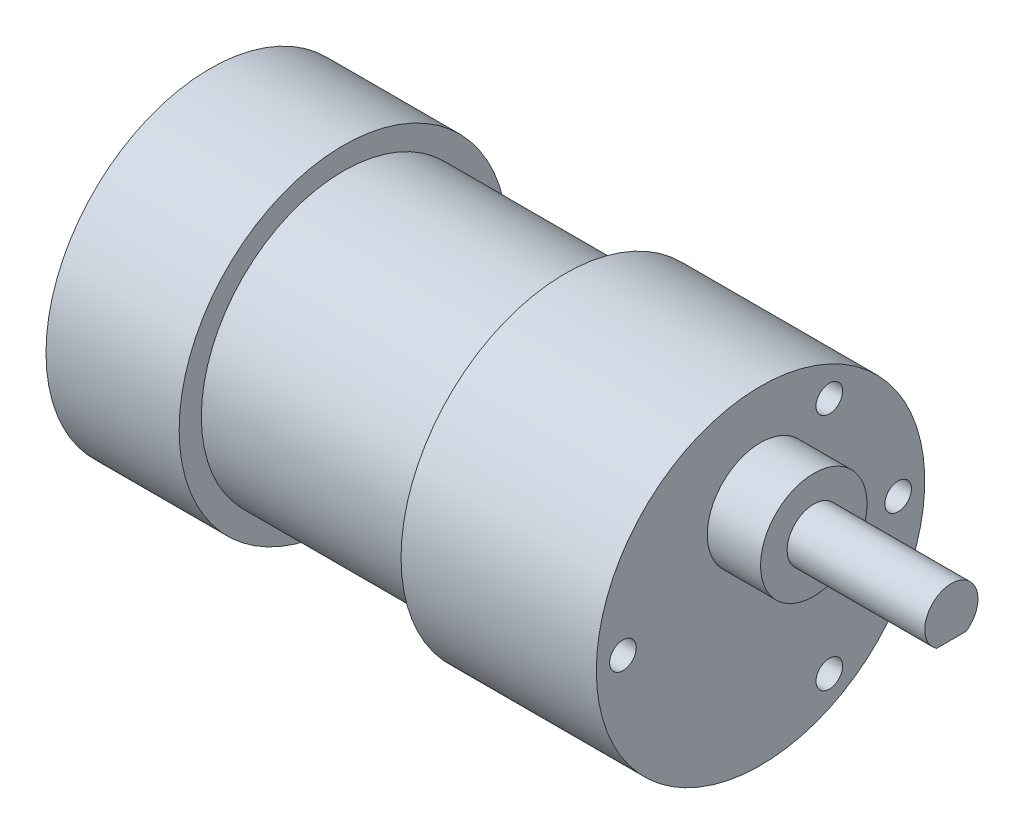
from build123d import *

# Parameters (mm, degrees)
ESQUISSE2_R             = 6
BOSS_EXTRU_1_DEPTH      = 6
ESQUISSE3_R             = 3
BOSS_EXTRU_2_DEPTH      = 15.5
ESQUISSE4_W             = 12
ESQUISSE4_H             = 0.5
ENL_V_MAT_EXTRU_1_DEPTH = 7.75
ESQUISSE5_R             = 1.5
ENL_V_MAT_EXTRU_2_DEPTH = 3.5
ESQUISSE6_W             = 3
ESQUISSE6_H             = 1
BOSS_EXTRU_3_DEPTH      = 4
ESQUISSE7_R             = 18.5
BOSS_EXTRU_4_DEPTH      = 10
BOSS_EXTRU_4_DEPTH_BACK = 5


with BuildPart() as part:
    # Esquisse1 → Révolution1 (revolve)
    with BuildSketch(Plane.XY):
        Polygon((0, 0), (0, 7), (7, 7), (7, 16), (37, 16), (37, 18.5), (59, 18.5), (59, 0), align=None)
    revolve(axis=Axis((0, 0, 0), (1, 0, 0)))

    # Esquisse2 → Boss.-Extru.1 (add)
    with BuildSketch(Plane(origin=(59, 0, 0), x_dir=(0, 0, -1), z_dir=(1, 0, 0))):
        with Locations((0, 7)):
            Circle(ESQUISSE2_R)
    extrude(amount=BOSS_EXTRU_1_DEPTH)

    # Esquisse3 → Boss.-Extru.2 (add)
    with BuildSketch(Plane(origin=(65, 0, 0), x_dir=(0, 0, -1), z_dir=(1, 0, 0))):
        with Locations((0, 7)):
            Circle(ESQUISSE3_R)
    extrude(amount=BOSS_EXTRU_2_DEPTH)

    # Esquisse4 → Enlèv. mat.-Extru.1 (cut, symmetric)
    with BuildSketch(Plane.XY):
        with Locations((74.5, 4.25)):
            Rectangle(ESQUISSE4_W, ESQUISSE4_H)
    extrude(amount=ENL_V_MAT_EXTRU_1_DEPTH, both=True, mode=Mode.SUBTRACT)

    # Esquisse5 → Enlèv. mat.-Extru.2 (cut)
    with BuildSketch(Plane(origin=(59, 0, 0), x_dir=(0, 0, -1), z_dir=(1, 0, 0))):
        with Locations((15.5, 0)):
            Circle(ESQUISSE5_R)
        with Locations((7.75, 13.423393759)):
            Circle(ESQUISSE5_R)
        with Locations((7.75, -13.423393759)):
            Circle(ESQUISSE5_R)
        with Locations((-15.5, 0)):
            Circle(ESQUISSE5_R)
    extrude(amount=-ENL_V_MAT_EXTRU_2_DEPTH, mode=Mode.SUBTRACT)

    # Esquisse6 → Boss.-Extru.3 (add)
    with BuildSketch(Plane.ZY.offset(-7)):
        with Locations((0, 12.939057981)):
            Rectangle(ESQUISSE6_W, ESQUISSE6_H)
        with Locations((0, -12.939057981)):
            Rectangle(ESQUISSE6_W, ESQUISSE6_H)
    extrude(amount=BOSS_EXTRU_3_DEPTH)

    # Esquisse7 → Boss.-Extru.4 (add, two sides)
    with BuildSketch(Plane.ZY.offset(-7)) as boss_extru_4_sk:
        Circle(ESQUISSE7_R)
    extrude(amount=BOSS_EXTRU_4_DEPTH)
    extrude(boss_extru_4_sk.sketch, amount=-BOSS_EXTRU_4_DEPTH_BACK)


solid = part.part
